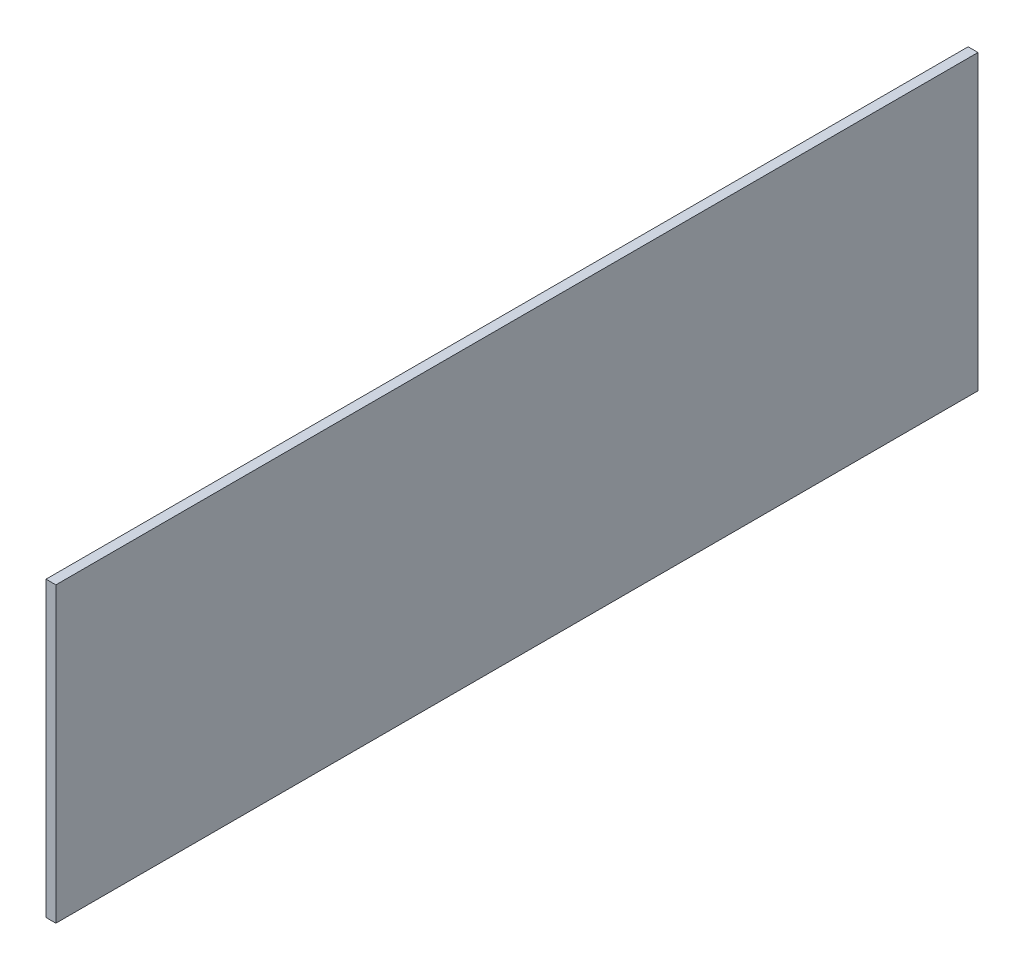
from build123d import *

# Parameters (mm, degrees)
SKETCH1_W           = 279.7556
SKETCH1_H           = 88.9
BOSS_EXTRUDE1_DEPTH = 2.9972


with BuildPart() as part:
    # Sketch1 → Boss-Extrude1 (new body)
    with BuildSketch(Plane(origin=(0, 0, 0), x_dir=(0, 0, -1), z_dir=(1, 0, 0))):
        with Locations((139.8778, -44.45)):
            Rectangle(SKETCH1_W, SKETCH1_H)
    extrude(amount=BOSS_EXTRUDE1_DEPTH)


solid = part.part
